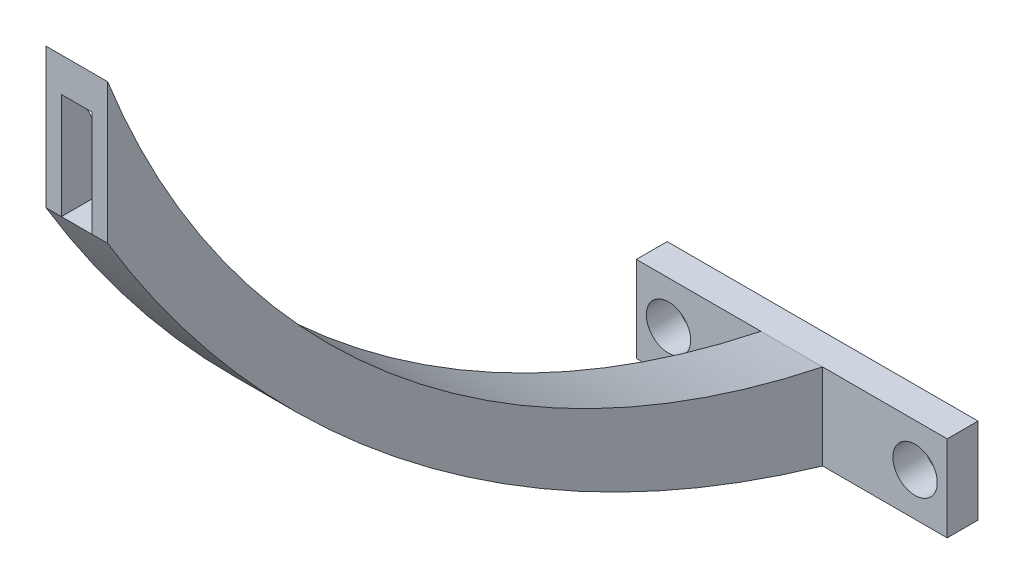
from build123d import *

# Parameters (mm, degrees)
SKETCH2_W           = 6.35
SKETCH2_H           = 73.66
BOSS_EXTRUDE1_DEPTH = 71.12
CUT_EXTRUDE1_DEPTH  = 71.12
SKETCH4_W           = 1.5875
SKETCH4_H           = 14.422052326
CUT_EXTRUDE2_DEPTH  = 71.12
SKETCH6_W           = 32.023370344
SKETCH6_H           = 8.840748178
SKETCH6_R           = 2.286
BOSS_EXTRUDE2_DEPTH = 3.175
BOSS_EXTRUDE3_DEPTH = 3.175


with BuildPart() as part:
    # Sketch2 → Boss-Extrude1 (new body)
    with BuildSketch(Plane(origin=(0, 0, 0), x_dir=(1, 0, 0), z_dir=(0, 1, 0))):
        with Locations((3.175, -36.83)):
            Rectangle(SKETCH2_W, SKETCH2_H)
    extrude(amount=BOSS_EXTRUDE1_DEPTH)

    # Sketch3 → Cut-Extrude1 (cut)
    with BuildSketch(Plane(origin=(6.35, 0, 0), x_dir=(0, 0, -1), z_dir=(1, 0, 0))):
        with BuildLine():
            ThreePointArc((0, 0), (-42.190194821, 21.385195311), (-73.66, 56.697947674))
            Line((-73.66, 56.697947674), (-73.66, 0))
            Line((-73.66, 0), (0, 0))
        make_face()
        with BuildLine():
            Line((0, 71.12), (-73.66, 71.12))
            ThreePointArc((-73.66, 71.12), (-44.704376489, 30.667054561), (0, 8.840748178))
            Line((0, 8.840748178), (0, 71.12))
        make_face()
    extrude(amount=-CUT_EXTRUDE1_DEPTH, mode=Mode.SUBTRACT)

    # Sketch4 → Cut-Extrude2 (cut)
    with BuildSketch(Plane.XY.offset(73.66)):
        with Locations((2.38125, 63.908973837)):
            Rectangle(SKETCH4_W, SKETCH4_H)
        with Locations((3.96875, 63.908973837)):
            Rectangle(SKETCH4_W, SKETCH4_H)
    extrude(amount=-CUT_EXTRUDE2_DEPTH, mode=Mode.SUBTRACT)

    # Sketch6 → Boss-Extrude2 (add)
    with BuildSketch(Plane(origin=(0, 0, 0), x_dir=(-1, 0, 0), z_dir=(0, 0, -1))):
        with Locations((-3.175, 4.420374089)):
            Rectangle(SKETCH6_W, SKETCH6_H)
        with Locations((-15.875, 4.420374089)):
            Circle(SKETCH6_R, mode=Mode.SUBTRACT)
        with Locations((9.525, 4.420374089)):
            Circle(SKETCH6_R, mode=Mode.SUBTRACT)
    extrude(amount=BOSS_EXTRUDE2_DEPTH)

    # Sketch7 → Boss-Extrude3 (add)
    with BuildSketch(Plane(origin=(1.5875, 0, 0), x_dir=(0, 0, -1), z_dir=(1, 0, 0))):
        Polygon((-73.66, 67.596150372), (-72.201792637, 67.596150372), (-73.66, 71.12), align=None)
    extrude(amount=BOSS_EXTRUDE3_DEPTH)


solid = part.part
